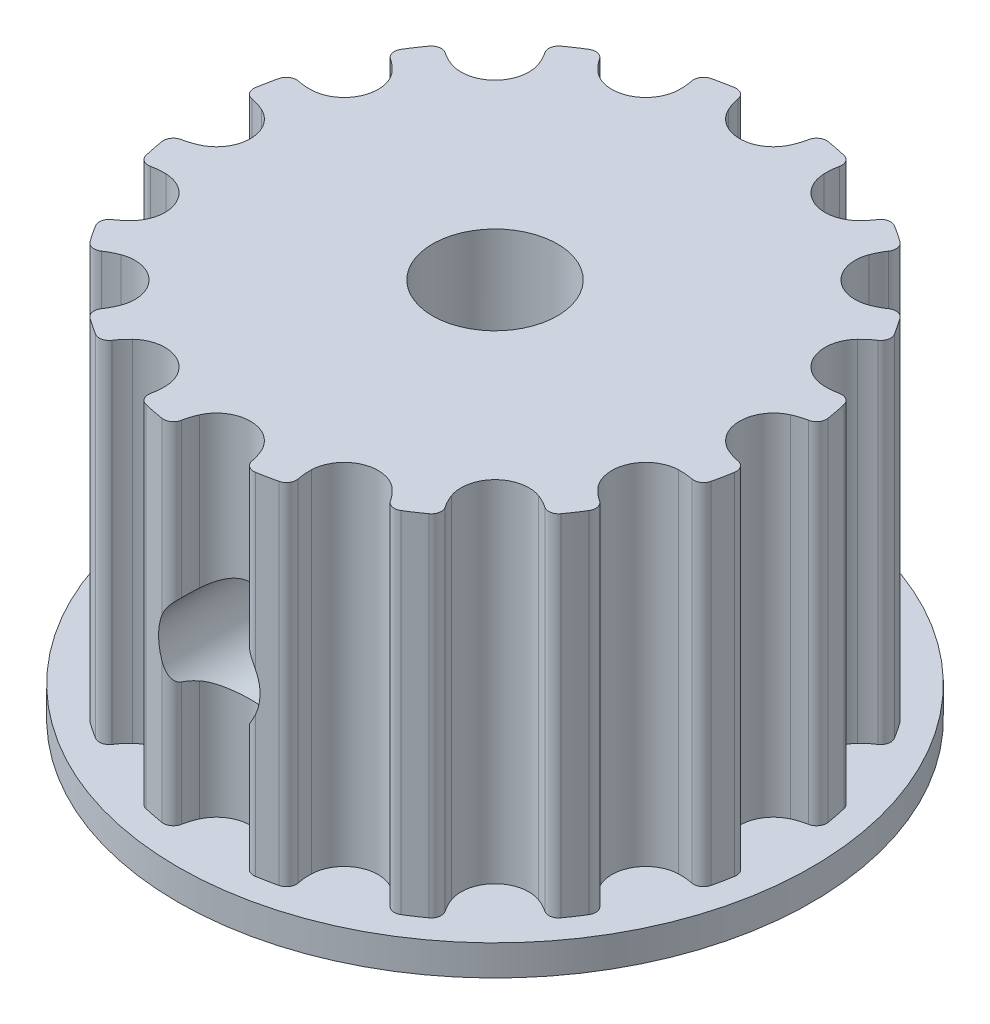
from build123d import *

# Parameters (mm, degrees)
SKETCH1_R               = 1.5625
BOSS_EXTRUDE1_DEPTH     = 4.7625
SKETCH2_R               = 7.9375
SKETCH2_R_2             = 1.5625
BOSS_EXTRUDE2_DEPTH     = 0.762
SKETCH5_R               = 1.27
CUT_EXTRUDE3_DEPTH      = 8.9375
CUT_EXTRUDE3_DEPTH_BACK = 8.9375


with BuildPart() as part:
    # Sketch1 → Boss-Extrude1 (new body, symmetric)
    with BuildSketch(Plane(origin=(0, 0, 0), x_dir=(1, 0, 0), z_dir=(0, 1, 0))):
        with BuildLine():
            ThreePointArc((-1.850768, -6.777037356), (-1.816941892, -6.962421006), (-1.663291889, -7.071521784))
            ThreePointArc((-1.663291889, -7.071521784), (-1.417233644, -7.124914669), (-1.169472895, -7.169748489))
            ThreePointArc((-1.169472895, -7.169748489), (-0.985767742, -7.127751824), (-0.883573242, -6.969424355))
            ThreePointArc((-0.883573242, -6.969424355), (-0.839120956, -6.792881518), (-0.773880597, -6.622919538))
            ThreePointArc((-0.773880597, -6.622919538), (0, -6.1245), (0.773880597, -6.622919538))
            ThreePointArc((0.773880597, -6.622919538), (0.839120956, -6.792881518), (0.883573242, -6.969424355))
            ThreePointArc((0.883573242, -6.969424355), (0.985767742, -7.127751824), (1.169472895, -7.169748489))
            ThreePointArc((1.169472895, -7.169748489), (1.417233644, -7.124914669), (1.663291889, -7.071521784))
            ThreePointArc((1.663291889, -7.071521784), (1.816941892, -6.962421006), (1.850768, -6.777037356))
            ThreePointArc((1.850768, -6.777037356), (1.824276538, -6.596921889), (1.819509137, -6.414931089))
            ThreePointArc((1.819509137, -6.414931089), (2.343744682, -5.658300197), (3.249454025, -5.822628523))
            ThreePointArc((3.249454025, -5.822628523), (3.374769892, -5.954686513), (3.483398468, -6.100779674))
            ThreePointArc((3.483398468, -6.100779674), (3.638403174, -6.20794704), (3.824196033, -6.176445981))
            ThreePointArc((3.824196033, -6.176445981), (4.035939958, -6.040210999), (4.242835561, -5.896719991))
            ThreePointArc((4.242835561, -5.896719991), (4.343038594, -5.737124705), (4.303346591, -5.552907854))
            ThreePointArc((4.303346591, -5.552907854), (4.209944466, -5.396640704), (4.135895098, -5.230327534))
            ThreePointArc((4.135895098, -5.230327534), (4.330675481, -4.330675481), (5.230327534, -4.135895098))
            ThreePointArc((5.230327534, -4.135895098), (5.396640704, -4.209944466), (5.552907854, -4.303346591))
            ThreePointArc((5.552907854, -4.303346591), (5.737124705, -4.343038594), (5.896719991, -4.242835561))
            ThreePointArc((5.896719991, -4.242835561), (6.040210999, -4.035939958), (6.176445981, -3.824196033))
            ThreePointArc((6.176445981, -3.824196033), (6.20794704, -3.638403174), (6.100779674, -3.483398468))
            ThreePointArc((6.100779674, -3.483398468), (5.954686513, -3.374769892), (5.822628523, -3.249454025))
            ThreePointArc((5.822628523, -3.249454025), (5.658300197, -2.343744682), (6.414931089, -1.819509137))
            ThreePointArc((6.414931089, -1.819509137), (6.596921889, -1.824276538), (6.777037356, -1.850768))
            ThreePointArc((6.777037356, -1.850768), (6.962421006, -1.816941892), (7.071521784, -1.663291889))
            ThreePointArc((7.071521784, -1.663291889), (7.124914669, -1.417233644), (7.169748489, -1.169472895))
            ThreePointArc((7.169748489, -1.169472895), (7.127751824, -0.985767742), (6.969424355, -0.883573242))
            ThreePointArc((6.969424355, -0.883573242), (6.792881518, -0.839120956), (6.622919538, -0.773880597))
            ThreePointArc((6.622919538, -0.773880597), (6.1245, 0), (6.622919538, 0.773880597))
            ThreePointArc((6.622919538, 0.773880597), (6.792881518, 0.839120956), (6.969424355, 0.883573242))
            ThreePointArc((6.969424355, 0.883573242), (7.127751824, 0.985767742), (7.169748489, 1.169472895))
            ThreePointArc((7.169748489, 1.169472895), (7.124914669, 1.417233644), (7.071521784, 1.663291889))
            ThreePointArc((7.071521784, 1.663291889), (6.962421006, 1.816941892), (6.777037356, 1.850768))
            ThreePointArc((6.777037356, 1.850768), (6.596921889, 1.824276538), (6.414931089, 1.819509137))
            ThreePointArc((6.414931089, 1.819509137), (5.658300197, 2.343744682), (5.822628523, 3.249454025))
            ThreePointArc((5.822628523, 3.249454025), (5.954686513, 3.374769892), (6.100779674, 3.483398468))
            ThreePointArc((6.100779674, 3.483398468), (6.20794704, 3.638403174), (6.176445981, 3.824196033))
            ThreePointArc((6.176445981, 3.824196033), (6.040210999, 4.035939958), (5.896719991, 4.242835561))
            ThreePointArc((5.896719991, 4.242835561), (5.737124705, 4.343038594), (5.552907854, 4.303346591))
            ThreePointArc((5.552907854, 4.303346591), (5.396640704, 4.209944466), (5.230327534, 4.135895098))
            ThreePointArc((5.230327534, 4.135895098), (4.330675481, 4.330675481), (4.135895098, 5.230327534))
            ThreePointArc((4.135895098, 5.230327534), (4.209944466, 5.396640704), (4.303346591, 5.552907854))
            ThreePointArc((4.303346591, 5.552907854), (4.343038594, 5.737124705), (4.242835561, 5.896719991))
            ThreePointArc((4.242835561, 5.896719991), (4.035939958, 6.040210999), (3.824196033, 6.176445981))
            ThreePointArc((3.824196033, 6.176445981), (3.638403174, 6.20794704), (3.483398468, 6.100779674))
            ThreePointArc((3.483398468, 6.100779674), (3.374769892, 5.954686513), (3.249454025, 5.822628523))
            ThreePointArc((3.249454025, 5.822628523), (2.343744682, 5.658300197), (1.819509137, 6.414931089))
            ThreePointArc((1.819509137, 6.414931089), (1.824276538, 6.596921889), (1.850768, 6.777037356))
            ThreePointArc((1.850768, 6.777037356), (1.816941892, 6.962421006), (1.663291889, 7.071521784))
            ThreePointArc((1.663291889, 7.071521784), (1.417233644, 7.124914669), (1.169472895, 7.169748489))
            ThreePointArc((1.169472895, 7.169748489), (0.985767742, 7.127751824), (0.883573242, 6.969424355))
            ThreePointArc((0.883573242, 6.969424355), (0.839120956, 6.792881518), (0.773880597, 6.622919538))
            ThreePointArc((0.773880597, 6.622919538), (0, 6.1245), (-0.773880597, 6.622919538))
            ThreePointArc((-0.773880597, 6.622919538), (-0.839120956, 6.792881518), (-0.883573242, 6.969424355))
            ThreePointArc((-0.883573242, 6.969424355), (-0.985767742, 7.127751824), (-1.169472895, 7.169748489))
            ThreePointArc((-1.169472895, 7.169748489), (-1.417233644, 7.124914669), (-1.663291889, 7.071521784))
            ThreePointArc((-1.663291889, 7.071521784), (-1.816941892, 6.962421006), (-1.850768, 6.777037356))
            ThreePointArc((-1.850768, 6.777037356), (-1.824276538, 6.596921889), (-1.819509137, 6.414931089))
            ThreePointArc((-1.819509137, 6.414931089), (-2.343744682, 5.658300197), (-3.249454025, 5.822628523))
            ThreePointArc((-3.249454025, 5.822628523), (-3.374769892, 5.954686513), (-3.483398468, 6.100779674))
            ThreePointArc((-3.483398468, 6.100779674), (-3.638403174, 6.20794704), (-3.824196033, 6.176445981))
            ThreePointArc((-3.824196033, 6.176445981), (-4.035939958, 6.040210999), (-4.242835561, 5.896719991))
            ThreePointArc((-4.242835561, 5.896719991), (-4.343038594, 5.737124705), (-4.303346591, 5.552907854))
            ThreePointArc((-4.303346591, 5.552907854), (-4.209944466, 5.396640704), (-4.135895098, 5.230327534))
            ThreePointArc((-4.135895098, 5.230327534), (-4.330675481, 4.330675481), (-5.230327534, 4.135895098))
            ThreePointArc((-5.230327534, 4.135895098), (-5.396640704, 4.209944466), (-5.552907854, 4.303346591))
            ThreePointArc((-5.552907854, 4.303346591), (-5.737124705, 4.343038594), (-5.896719991, 4.242835561))
            ThreePointArc((-5.896719991, 4.242835561), (-6.040210999, 4.035939958), (-6.176445981, 3.824196033))
            ThreePointArc((-6.176445981, 3.824196033), (-6.20794704, 3.638403174), (-6.100779674, 3.483398468))
            ThreePointArc((-6.100779674, 3.483398468), (-5.954686513, 3.374769892), (-5.822628523, 3.249454025))
            ThreePointArc((-5.822628523, 3.249454025), (-5.658300197, 2.343744682), (-6.414931089, 1.819509137))
            ThreePointArc((-6.414931089, 1.819509137), (-6.596921889, 1.824276538), (-6.777037356, 1.850768))
            ThreePointArc((-6.777037356, 1.850768), (-6.962421006, 1.816941892), (-7.071521784, 1.663291889))
            ThreePointArc((-7.071521784, 1.663291889), (-7.124914669, 1.417233644), (-7.169748489, 1.169472895))
            ThreePointArc((-7.169748489, 1.169472895), (-7.127751824, 0.985767742), (-6.969424355, 0.883573242))
            ThreePointArc((-6.969424355, 0.883573242), (-6.792881518, 0.839120956), (-6.622919538, 0.773880597))
            ThreePointArc((-6.622919538, 0.773880597), (-6.1245, 0), (-6.622919538, -0.773880597))
            ThreePointArc((-6.622919538, -0.773880597), (-6.792881518, -0.839120956), (-6.969424355, -0.883573242))
            ThreePointArc((-6.969424355, -0.883573242), (-7.127751824, -0.985767742), (-7.169748489, -1.169472895))
            ThreePointArc((-7.169748489, -1.169472895), (-7.124914669, -1.417233644), (-7.071521784, -1.663291889))
            ThreePointArc((-7.071521784, -1.663291889), (-6.962421006, -1.816941892), (-6.777037356, -1.850768))
            ThreePointArc((-6.777037356, -1.850768), (-6.596921889, -1.824276538), (-6.414931089, -1.819509137))
            ThreePointArc((-6.414931089, -1.819509137), (-5.658300197, -2.343744682), (-5.822628523, -3.249454025))
            ThreePointArc((-5.822628523, -3.249454025), (-5.954686513, -3.374769892), (-6.100779674, -3.483398468))
            ThreePointArc((-6.100779674, -3.483398468), (-6.20794704, -3.638403174), (-6.176445981, -3.824196033))
            ThreePointArc((-6.176445981, -3.824196033), (-6.040210999, -4.035939958), (-5.896719991, -4.242835561))
            ThreePointArc((-5.896719991, -4.242835561), (-5.737124705, -4.343038594), (-5.552907854, -4.303346591))
            ThreePointArc((-5.552907854, -4.303346591), (-5.396640704, -4.209944466), (-5.230327534, -4.135895098))
            ThreePointArc((-5.230327534, -4.135895098), (-4.330675481, -4.330675481), (-4.135895098, -5.230327534))
            ThreePointArc((-4.135895098, -5.230327534), (-4.209944466, -5.396640704), (-4.303346591, -5.552907854))
            ThreePointArc((-4.303346591, -5.552907854), (-4.343038594, -5.737124705), (-4.242835561, -5.896719991))
            ThreePointArc((-4.242835561, -5.896719991), (-4.035939958, -6.040210999), (-3.824196033, -6.176445981))
            ThreePointArc((-3.824196033, -6.176445981), (-3.638403174, -6.20794704), (-3.483398468, -6.100779674))
            ThreePointArc((-3.483398468, -6.100779674), (-3.374769892, -5.954686513), (-3.249454025, -5.822628523))
            ThreePointArc((-3.249454025, -5.822628523), (-2.343744682, -5.658300197), (-1.819509137, -6.414931089))
            ThreePointArc((-1.819509137, -6.414931089), (-1.824276538, -6.596921889), (-1.850768, -6.777037356))
        make_face()
        Circle(SKETCH1_R, mode=Mode.SUBTRACT)
    extrude(amount=BOSS_EXTRUDE1_DEPTH, both=True)

    # Sketch2 → Boss-Extrude2 (add)
    with BuildSketch(Plane.XZ.offset(4.7625)):
        Circle(SKETCH2_R)
        Circle(SKETCH2_R_2, mode=Mode.SUBTRACT)
    extrude(amount=-BOSS_EXTRUDE2_DEPTH)

    # Sketch5 → Cut-Extrude3 (cut, two sides)
    with BuildSketch(Plane.XY) as cut_extrude3_sk:
        Circle(SKETCH5_R)
    extrude(amount=CUT_EXTRUDE3_DEPTH, mode=Mode.SUBTRACT)
    extrude(cut_extrude3_sk.sketch, amount=-CUT_EXTRUDE3_DEPTH_BACK, mode=Mode.SUBTRACT)


solid = part.part
